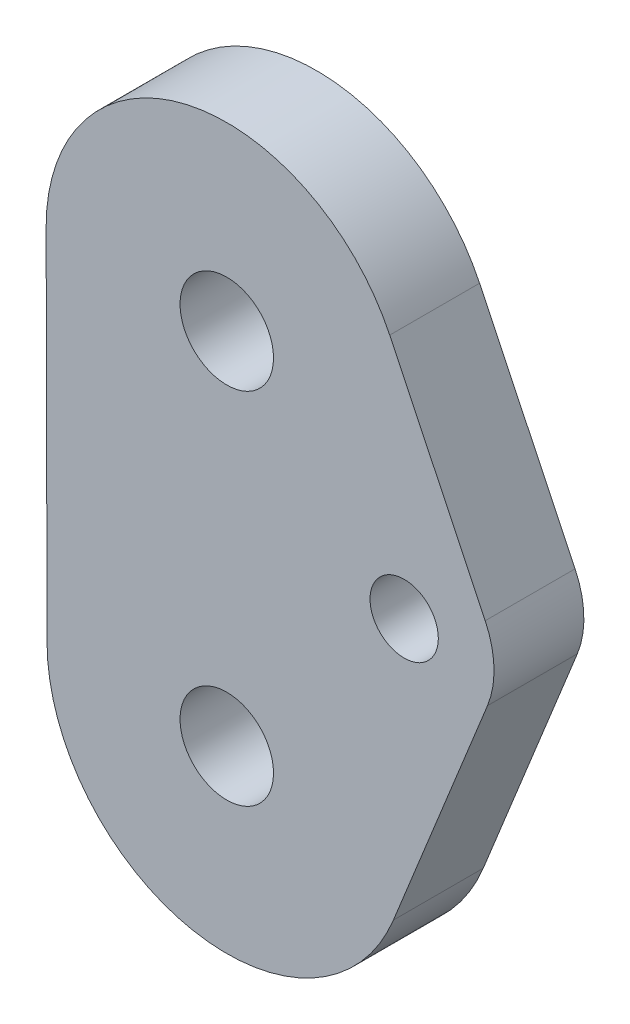
from build123d import *

# Parameters (mm, degrees)
SKETCH1_R           = 2.413
SKETCH1_R_2         = 3.302
BOSS_EXTRUDE1_DEPTH = 6.35


with BuildPart() as part:
    # Sketch1 → Boss-Extrude1 (new body)
    with BuildSketch(Plane.XY):
        with BuildLine():
            Line((62.872947054, -55.8231681), (56.224170085, -72.268872447))
            ThreePointArc((56.224170085, -72.268872447), (42.041303725, -79.978223974), (31.750041687, -67.541273993))
            Line((31.750041687, -67.541273993), (31.684961751, -42.141440742))
            ThreePointArc((31.684961751, -42.141440742), (41.60885576, -29.663848597), (55.964520416, -36.598462524))
            Line((55.964520416, -36.598462524), (62.713770006, -50.702009635))
            ThreePointArc((62.713770006, -50.702009635), (63.332796848, -53.245821919), (62.872947054, -55.8231681))
        make_face()
        with Locations((56.985862012, -53.443098836)):
            Circle(SKETCH1_R, mode=Mode.SUBTRACT)
        with Locations((44.45, -67.508733918)):
            Circle(SKETCH1_R_2, mode=Mode.SUBTRACT)
        with Locations((44.45, -42.108733918)):
            Circle(SKETCH1_R_2, mode=Mode.SUBTRACT)
    extrude(amount=BOSS_EXTRUDE1_DEPTH)


solid = part.part
